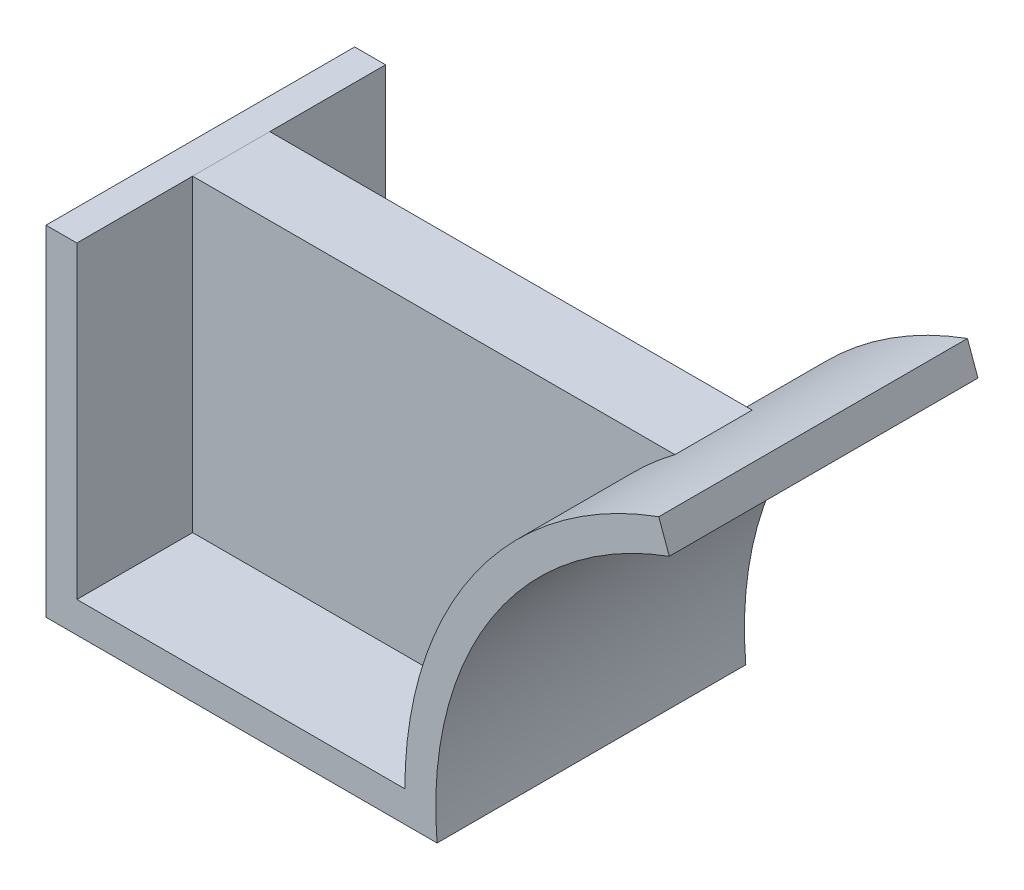
from build123d import *

# Parameters (mm, degrees)
EXTRUDE_THIN1_DEPTH = 80
BOSS_EXTRUDE2_REACH = 155.534
SKETCH2_W           = 20
SKETCH2_H           = 80


with BuildPart() as part:
    # Sketch1 → Extrude-Thin1 (new body)
    with BuildSketch(Plane.XY):
        with BuildLine():
            ThreePointArc((150.797985667, 93.969262079), (103.084795571, 57.357643635), (85, 0))
            Line((85, 0), (0, 0))
            Line((0, 0), (0, 80))
            Line((0, 80), (-8, 80))
            Line((-8, 80), (-8, -8))
            Line((-8, -8), (93.348486101, -8))
            ThreePointArc((93.348486101, -8), (107.412930041, 49.439322156), (153.534146814, 86.451721112))
            Line((153.534146814, 86.451721112), (150.797985667, 93.969262079))
        make_face()
    extrude(amount=EXTRUDE_THIN1_DEPTH)


with BuildPart() as body_2:

    # Sketch2 → Boss-Extrude2 (new body, up to next)
    with BuildSketch(Plane(origin=(0, 0, 0), x_dir=(0, 0, -1), z_dir=(1, 0, 0)), mode=Mode.PRIVATE) as boss_extrude2_sk1:
        with Locations((-40, 40)):
            Rectangle(SKETCH2_W, SKETCH2_H)
    boss_extrude2_tool1 = extrude(boss_extrude2_sk1.sketch, amount=BOSS_EXTRUDE2_REACH, mode=Mode.PRIVATE) - part.part
    add(boss_extrude2_tool1.solids().sort_by_distance((0, 40, 40))[0])


solid = Compound([part.part, body_2.part])
